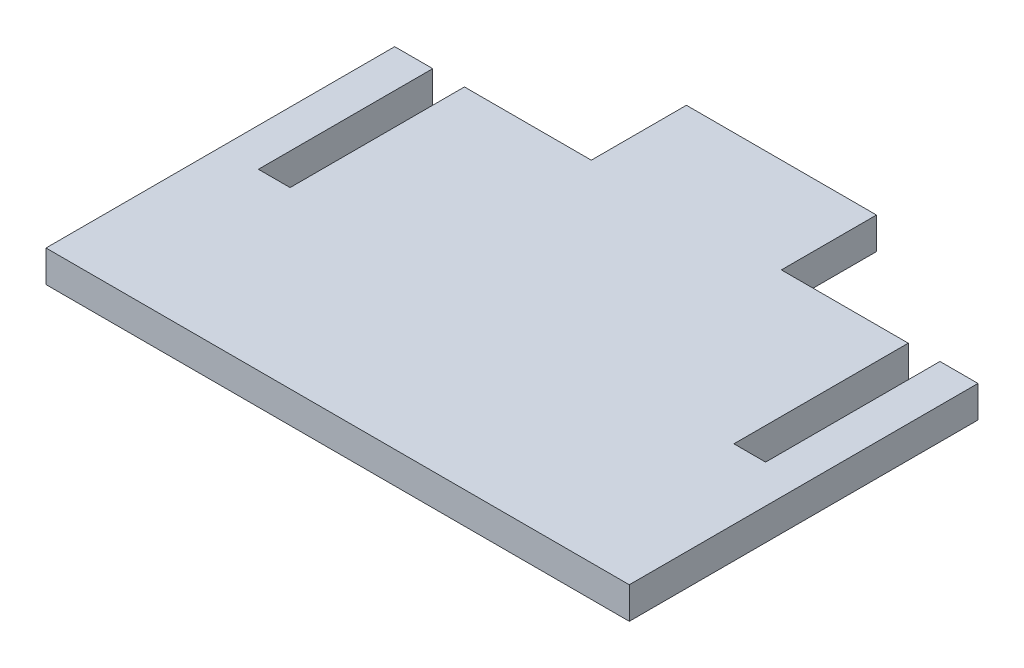
from build123d import *

# Parameters (mm, degrees)
SKETCH1_W           = 92
SKETCH1_H           = 55
BOSS_EXTRUDE1_DEPTH = 2.5
SKETCH2_W           = 5
SKETCH2_H           = 27.5
CUT_EXTRUDE1_DEPTH  = 6
SKETCH3_W           = 29.98
SKETCH3_H           = 15
BOSS_EXTRUDE2_DEPTH = 5


with BuildPart() as part:
    # Sketch1 → Boss-Extrude1 (new body, symmetric)
    with BuildSketch(Plane(origin=(0, 0, 0), x_dir=(1, 0, 0), z_dir=(0, 1, 0))):
        Rectangle(SKETCH1_W, SKETCH1_H)
    extrude(amount=BOSS_EXTRUDE1_DEPTH, both=True)

    # Sketch2 → Cut-Extrude1 (cut, through all)
    with BuildSketch(Plane(origin=(0, 2.5, 0), x_dir=(1, 0, 0), z_dir=(0, 1, 0))):
        with Locations((-37.5, 13.75)):
            Rectangle(SKETCH2_W, SKETCH2_H)
        with Locations((37.5, 13.75)):
            Rectangle(SKETCH2_W, SKETCH2_H)
    extrude(amount=-CUT_EXTRUDE1_DEPTH, mode=Mode.SUBTRACT)

    # Sketch3 → Boss-Extrude2 (add)
    with BuildSketch(Plane(origin=(0, 2.5, 0), x_dir=(1, 0, 0), z_dir=(0, 1, 0))):
        with Locations((0, 35)):
            Rectangle(SKETCH3_W, SKETCH3_H)
    extrude(amount=-BOSS_EXTRUDE2_DEPTH)


solid = part.part
